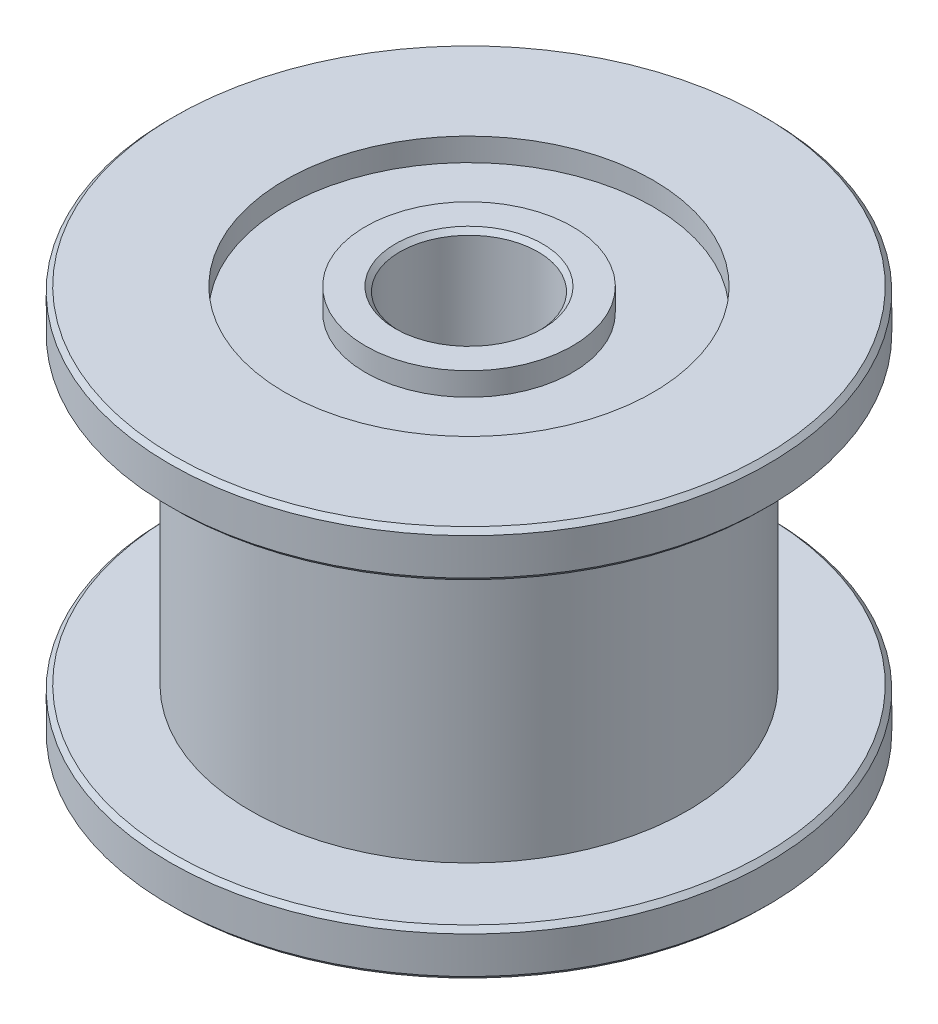
from build123d import *

# Parameters (mm, degrees)
CHAMFER1_SIZE      = 0.1
SKETCH2_R          = 4
SKETCH2_R_2        = 2.25
CUT_EXTRUDE1_DEPTH = 0.5


with BuildPart() as part:
    # Sketch1 → Revolve1 (revolve)
    with BuildSketch(Plane(origin=(0, 0, 0), x_dir=(0, 0, -1), z_dir=(1, 0, 0))):
        Polygon((1.5, -4.25), (1.5, 4.25), (6.5, 4.25), (6.5, 3.25), (4.75, 3.25), (4.75, -3.25), (6.5, -3.25), (6.5, -4.25), align=None)
    revolve(axis=Axis((0, 0, 0), (0, 1, 0)))

    # Chamfer1
    chamfer1_edges = [part.edges().sort_by_distance(p)[0] for p in [
        (0, -4.25, 1.5),
        (0, -4.25, 6.5),
        (0, -3.25, 6.5),
        (0, 3.25, 6.5),
        (0, 4.25, 6.5),
        (0, 4.25, 1.5),
    ]]
    chamfer(chamfer1_edges, length=CHAMFER1_SIZE)

    # Sketch2 → Cut-Extrude1 (cut)
    with BuildSketch(Plane(origin=(0, 4.25, 0), x_dir=(1, 0, 0), z_dir=(0, 1, 0))):
        Circle(SKETCH2_R)
        Circle(SKETCH2_R_2, mode=Mode.SUBTRACT)
    cut_extrude1 = extrude(amount=-CUT_EXTRUDE1_DEPTH, mode=Mode.SUBTRACT)

    # Mirror1: Cut-Extrude1 across plane
    add(cut_extrude1.mirror(Plane.ZX), mode=Mode.SUBTRACT)


solid = part.part
